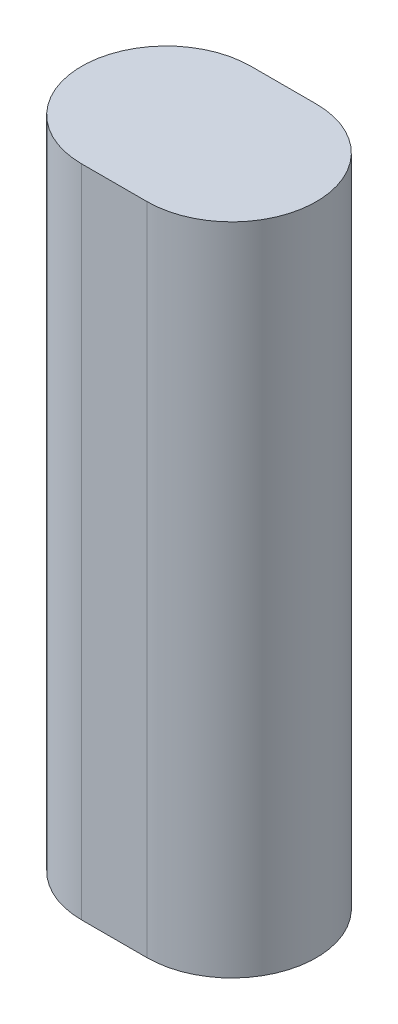
from build123d import *

# Parameters (mm, degrees)
BOSS_EXTRUDE2_DEPTH = 120


with BuildPart() as part:
    # Sketch1 → Boss-Extrude2 (new body)
    with BuildSketch(Plane(origin=(0, 0, 0), x_dir=(1, 0, 0), z_dir=(0, 1, 0))):
        with BuildLine():
            Line((0, 15.5), (12, 15.5))
            ThreePointArc((12, 15.5), (27.5, 0), (12, -15.5))
            Line((12, -15.5), (0, -15.5))
            ThreePointArc((0, -15.5), (-15.5, 0), (0, 15.5))
        make_face()
    extrude(amount=BOSS_EXTRUDE2_DEPTH)


solid = part.part
